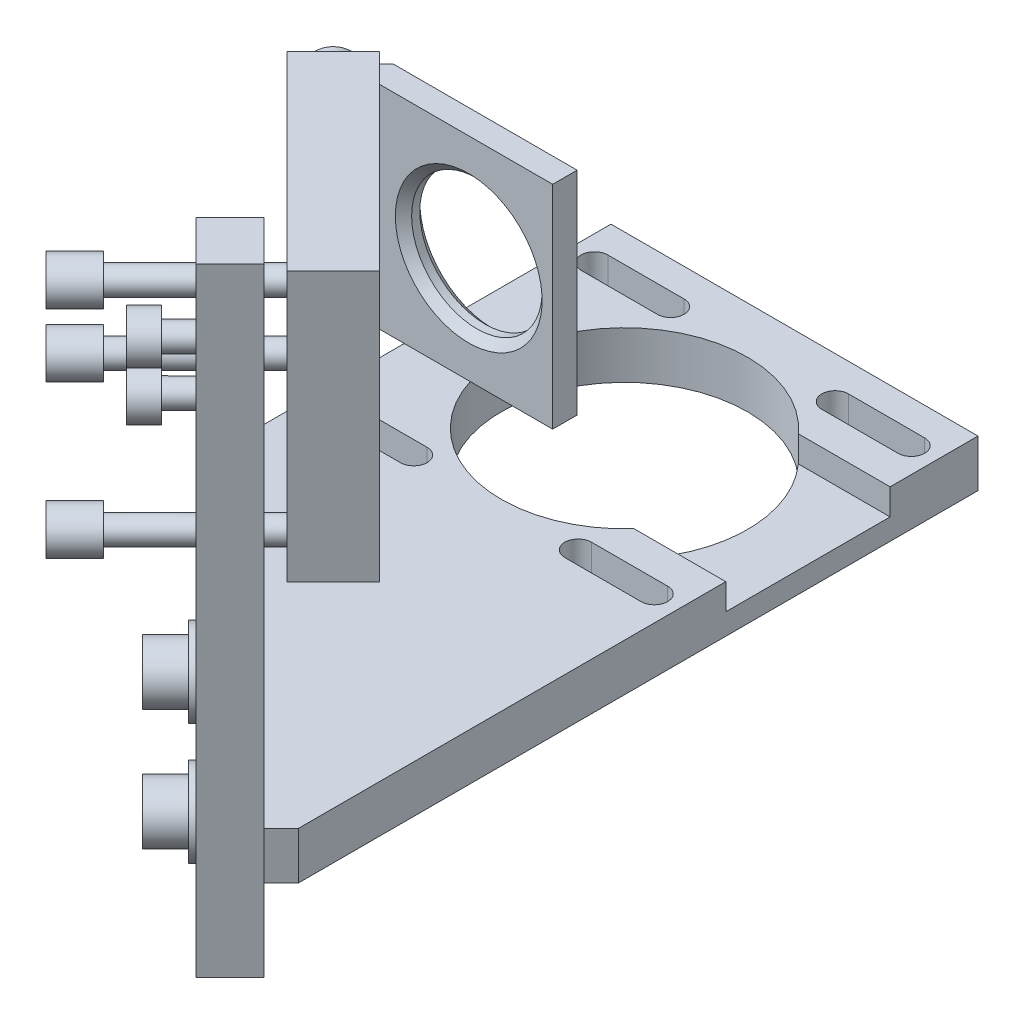
from build123d import *

# Parameters (mm, degrees)
SKETCH1_W                = 49.9
SKETCH1_H                = 49.9
BOSS_EXTRUDE1_DEPTH      = 6
BOSS_EXTRUDE2_DEPTH      = 5.9
SKETCH3_R                = 1.5
BOSS_EXTRUDE3_DEPTH      = 13
BOSS_EXTRUDE3_DEPTH_BACK = 14.9
SKETCH4_R                = 2.5
BOSS_EXTRUDE4_DEPTH      = 5
SKETCH5_R                = 1.5
BOSS_EXTRUDE5_DEPTH      = 3
SKETCH6_R                = 2.75
BOSS_EXTRUDE6_DEPTH      = 0.5
SKETCH7_R                = 2.75
BOSS_EXTRUDE7_DEPTH      = 2.5
SKETCH8_W                = 33
SKETCH8_H                = 33
SKETCH8_R                = 8.675
BOSS_EXTRUDE8_DEPTH      = 1
SKETCH9_W                = 33
SKETCH9_H                = 33
SKETCH9_R                = 10.15
BOSS_EXTRUDE9_DEPTH      = 7
SKETCH10_R               = 10
BOSS_EXTRUDE10_DEPTH     = 2
SKETCH11_R               = 10.15
SKETCH11_R_2             = 6
BOSS_EXTRUDE11_DEPTH     = 3
SKETCH12_R               = 2
CUT_EXTRUDE1_DEPTH       = 13
SKETCH13_R               = 4
CUT_EXTRUDE2_DEPTH       = 4
SKETCH14_R               = 3.5
BOSS_EXTRUDE12_DEPTH     = 1
SKETCH15_R               = 3.5
BOSS_EXTRUDE13_DEPTH     = 3
BOSS_EXTRUDE14_DEPTH     = 13
SKETCH17_R               = 8
CUT_EXTRUDE3_DEPTH       = 3
CHAMFER1_SIZE            = 1
SKETCH18_R               = 2.75
BOSS_EXTRUDE15_DEPTH     = 0.5
SKETCH19_R               = 2.75
BOSS_EXTRUDE16_DEPTH     = 2.5
SKETCH20_W               = 97.923574324
SKETCH20_H               = 110.172602672
CUT_EXTRUDE4_DEPTH       = 23
BOSS_EXTRUDE17_DEPTH     = 42
CUT_EXTRUDE5_DEPTH       = 35.775
SKETCH23_R               = 15.1
BOSS_EXTRUDE18_DEPTH     = 5.8
CUT_EXTRUDE6_DEPTH       = 3.2
SKETCH25_R               = 4.5
BOSS_EXTRUDE19_DEPTH     = 0.65
SKETCH26_R               = 3.25
BOSS_EXTRUDE20_DEPTH     = 1
SKETCH27_R               = 3.25
BOSS_EXTRUDE21_DEPTH     = 3


with BuildPart() as part:
    # Sketch1 → Boss-Extrude1 (new body)
    with BuildSketch(Plane(origin=(0, -32.5, 0), x_dir=(1, 0, 0), z_dir=(0, 1, 0))):
        with Locations((-9.95, -9.95)):
            Rectangle(SKETCH1_W, SKETCH1_H)
        with BuildLine():
            Line((1.05, 8.3), (10.05, 8.3))
            ThreePointArc((10.05, 8.3), (12.55, 5.8), (10.05, 3.3))
            Line((10.05, 3.3), (1.05, 3.3))
            ThreePointArc((1.05, 3.3), (-1.45, 5.8), (1.05, 8.3))
        make_face(mode=Mode.SUBTRACT)
        with BuildLine():
            Line((-20.95, 8.3), (-29.95, 8.3))
            ThreePointArc((-29.95, 8.3), (-32.45, 5.8), (-29.95, 3.3))
            Line((-29.95, 3.3), (-20.95, 3.3))
            ThreePointArc((-20.95, 3.3), (-18.45, 5.8), (-20.95, 8.3))
        make_face(mode=Mode.SUBTRACT)
        with BuildLine():
            Line((-20.95, -28.2), (-29.95, -28.2))
            ThreePointArc((-29.95, -28.2), (-32.45, -25.7), (-29.95, -23.2))
            Line((-29.95, -23.2), (-20.95, -23.2))
            ThreePointArc((-20.95, -23.2), (-18.45, -25.7), (-20.95, -28.2))
        make_face(mode=Mode.SUBTRACT)
        with BuildLine():
            Line((1.05, -28.2), (10.05, -28.2))
            ThreePointArc((10.05, -28.2), (12.55, -25.7), (10.05, -23.2))
            Line((10.05, -23.2), (1.05, -23.2))
            ThreePointArc((1.05, -23.2), (-1.45, -25.7), (1.05, -28.2))
        make_face(mode=Mode.SUBTRACT)
    extrude(amount=-BOSS_EXTRUDE1_DEPTH)

    # Sketch2 → Boss-Extrude2 (add)
    with BuildSketch(Plane(origin=(-6.363961031, 0, 6.363961031), x_dir=(0, -1, 0), z_dir=(0.707106781, 0, -0.707106781))):
        with BuildLine():
            Line((-5.545268253, -9.5), (-17.25, -9.5))
            Line((-17.25, -9.5), (-17.25, -16.5))
            Line((-17.25, -16.5), (32.5, -16.5))
            Line((32.5, -16.5), (32.5, 16.5))
            Line((32.5, 16.5), (8.9, 16.5))
            Line((8.9, 16.5), (8.9, 6.464518544))
            ThreePointArc((8.9, 6.464518544), (8.156593612, -7.380378083), (-5.545268253, -9.5))
        make_face()
    extrude(amount=-BOSS_EXTRUDE2_DEPTH)

    # Sketch3 → Boss-Extrude3 (add, two sides)
    with BuildSketch(Plane(origin=(-10.53589104, 0, 10.53589104), x_dir=(0.707106781, 0, 0.707106781), z_dir=(-0.707106781, 0, 0.707106781))) as boss_extrude3_sk:
        with Locations((13.25, 13.25)):
            Circle(SKETCH3_R)
        with Locations((13.25, -13.25)):
            Circle(SKETCH3_R)
        with Locations((-13.25, -13.25)):
            Circle(SKETCH3_R)
    extrude(amount=BOSS_EXTRUDE3_DEPTH)
    extrude(boss_extrude3_sk.sketch, amount=-BOSS_EXTRUDE3_DEPTH_BACK)

    # Sketch4 → Boss-Extrude4 (add)
    with BuildSketch(Plane(origin=(-19.728279195, 0, 19.728279195), x_dir=(0.707106781, 0, 0.707106781), z_dir=(-0.707106781, 0, 0.707106781))):
        with Locations((13.25, 13.25)):
            Circle(SKETCH4_R)
        with Locations((13.25, -13.25)):
            Circle(SKETCH4_R)
        with Locations((-13.25, -13.25)):
            Circle(SKETCH4_R)
    extrude(amount=-BOSS_EXTRUDE4_DEPTH)

    # Sketch5 → Boss-Extrude5 (add)
    with BuildSketch(Plane(origin=(-10.53589104, 0, 10.53589104), x_dir=(0.707106781, 0, 0.707106781), z_dir=(-0.707106781, 0, 0.707106781))):
        with Locations((-7.25, -13.25)):
            Circle(SKETCH5_R)
        with Locations((13.25, 7.25)):
            Circle(SKETCH5_R)
    extrude(amount=BOSS_EXTRUDE5_DEPTH)

    # Sketch6 → Boss-Extrude6 (add)
    with BuildSketch(Plane(origin=(-12.657211383, 0, 12.657211383), x_dir=(0.707106781, 0, 0.707106781), z_dir=(-0.707106781, 0, 0.707106781))):
        with Locations((13.25, 7.25)):
            Circle(SKETCH6_R)
        with Locations((-7.25, -13.25)):
            Circle(SKETCH6_R)
    extrude(amount=BOSS_EXTRUDE6_DEPTH)

    # Sketch7 → Boss-Extrude7 (add)
    with BuildSketch(Plane(origin=(-13.010764774, 0, 13.010764774), x_dir=(0.707106781, 0, 0.707106781), z_dir=(-0.707106781, 0, 0.707106781))):
        with Locations((-7.25, -13.25)):
            Circle(SKETCH7_R)
        Polygon((-6.221372178, -12.237449687), (-7.612580383, -11.852907018), (-8.641208205, -12.865457332), (-8.278627822, -14.262550313), (-6.887419617, -14.647092982), (-5.858791795, -13.634542668), align=None, mode=Mode.SUBTRACT)
        with Locations((13.25, 7.25)):
            Circle(SKETCH7_R)
        Polygon((13.787086733, 5.910271978), (14.678781868, 7.045266744), (14.141695135, 8.384994766), (12.712913267, 8.589728022), (11.821218132, 7.454733256), (12.358304865, 6.115005234), align=None, mode=Mode.SUBTRACT)
    extrude(amount=BOSS_EXTRUDE7_DEPTH)

    # Sketch8 → Boss-Extrude8 (add)
    with BuildSketch(Plane(origin=(0, 0, 0), x_dir=(0, -1, 0), z_dir=(0.707106781, 0, -0.707106781))):
        Rectangle(SKETCH8_W, SKETCH8_H)
        Circle(SKETCH8_R, mode=Mode.SUBTRACT)
    extrude(amount=BOSS_EXTRUDE8_DEPTH)

    # Sketch9 → Boss-Extrude9 (add)
    with BuildSketch(Plane(origin=(0, 0, 0), x_dir=(0.707106781, 0, 0.707106781), z_dir=(-0.707106781, 0, 0.707106781))):
        Rectangle(SKETCH9_W, SKETCH9_H)
        Circle(SKETCH9_R, mode=Mode.SUBTRACT)
    extrude(amount=BOSS_EXTRUDE9_DEPTH)

    # Sketch10 → Boss-Extrude10 (add)
    with BuildSketch(Plane(origin=(0, 0, 0), x_dir=(0.707106781, 0, 0.707106781), z_dir=(-0.707106781, 0, 0.707106781))):
        Circle(SKETCH10_R)
    extrude(amount=BOSS_EXTRUDE10_DEPTH)

    # Sketch11 → Boss-Extrude11 (add)
    with BuildSketch(Plane(origin=(-1.414213562, 0, 1.414213562), x_dir=(0.707106781, 0, 0.707106781), z_dir=(-0.707106781, 0, 0.707106781))):
        Circle(SKETCH11_R)
        Circle(SKETCH11_R_2, mode=Mode.SUBTRACT)
    extrude(amount=BOSS_EXTRUDE11_DEPTH)

    # Sketch12 → Cut-Extrude1 (cut)
    with BuildSketch(Plane.XZ.offset(38.5)):
        with Locations((-15.344217152, 1.555634919)):
            Circle(SKETCH12_R)
        with Locations((-1.555634919, 15.344217152)):
            Circle(SKETCH12_R)
    extrude(amount=-CUT_EXTRUDE1_DEPTH, mode=Mode.SUBTRACT)

    # Sketch13 → Cut-Extrude2 (cut)
    with BuildSketch(Plane.XZ.offset(38.5)):
        with Locations((-15.344217152, 1.555634919)):
            Circle(SKETCH13_R)
        with Locations((-1.555634919, 15.344217152)):
            Circle(SKETCH13_R)
    extrude(amount=-CUT_EXTRUDE2_DEPTH, mode=Mode.SUBTRACT)

    # Sketch14 → Boss-Extrude12 (add)
    with BuildSketch(Plane.XZ.offset(34.5)):
        with Locations((-15.344217152, 1.555634919)):
            Circle(SKETCH14_R)
        with Locations((-1.555634919, 15.344217152)):
            Circle(SKETCH14_R)
    extrude(amount=BOSS_EXTRUDE12_DEPTH)

    # Sketch15 → Boss-Extrude13 (add)
    with BuildSketch(Plane.XZ.offset(35.5)):
        with Locations((-1.555634919, 15.344217152)):
            Circle(SKETCH15_R)
        Polygon((-2.665434879, 16.674008131), (-3.262167668, 15.047997683), (-2.152367708, 13.718206703), (-0.445834958, 14.014426173), (0.150897831, 15.640436621), (-0.958902129, 16.9702276), align=None, mode=Mode.SUBTRACT)
        with Locations((-15.344217152, 1.555634919)):
            Circle(SKETCH15_R)
        Polygon((-14.297928697, 2.935953893), (-16.016464221, 3.151906787), (-17.062752676, 1.771587813), (-16.390505606, 0.175315945), (-14.671970082, -0.04063695), (-13.625681628, 1.339682024), align=None, mode=Mode.SUBTRACT)
    extrude(amount=BOSS_EXTRUDE13_DEPTH)

    # Sketch16 → Boss-Extrude14 (add, symmetric)
    with BuildSketch(Plane(origin=(0, 0, 0), x_dir=(1, 0, 0), z_dir=(0, 1, 0))):
        Polygon((-10.960155108, 12.374368671), (-16.263455967, 7.071067812), (-18.384776311, 9.192388155), (-12.202795796, 15.374368671), (10.289844892, 15.374368671), (10.289844892, 12.374368671), align=None)
    extrude(amount=BOSS_EXTRUDE14_DEPTH, both=True)

    # Sketch17 → Cut-Extrude3 (cut)
    with BuildSketch(Plane(origin=(0, 0, -15.374368671), x_dir=(-1, 0, 0), z_dir=(0, 0, -1))):
        Circle(SKETCH17_R)
    extrude(amount=-CUT_EXTRUDE3_DEPTH, mode=Mode.SUBTRACT)

    # Chamfer1
    chamfer1_edges = [part.edges().sort_by_distance(p)[0] for p in [
        (8, 0, -12.374368671),
        (8, 0, -15.374368671),
    ]]
    chamfer(chamfer1_edges, length=CHAMFER1_SIZE)

    # Sketch18 → Boss-Extrude15 (add)
    with BuildSketch(Plane(origin=(-13.788582233, 0, -13.788582233), x_dir=(-0.707106781, 0, 0.707106781), z_dir=(-0.707106781, 0, -0.707106781))):
        with Locations((3, 10)):
            Circle(SKETCH18_R)
        with Locations((3, -10)):
            Circle(SKETCH18_R)
    extrude(amount=BOSS_EXTRUDE15_DEPTH)

    # Sketch19 → Boss-Extrude16 (add)
    with BuildSketch(Plane(origin=(-14.142135624, 0, -14.142135624), x_dir=(-0.707106781, 0, 0.707106781), z_dir=(-0.707106781, 0, -0.707106781))):
        with Locations((3, -10)):
            Circle(SKETCH19_R)
        Polygon((3.666920263, -11.280058865), (4.442023626, -10.062459543), (3.775103364, -8.782400678), (2.333079737, -8.719941135), (1.557976374, -9.937540457), (2.224896636, -11.217599322), align=None, mode=Mode.SUBTRACT)
        with Locations((3, 10)):
            Circle(SKETCH19_R)
        Polygon((1.848210491, 9.130106754), (3.177454895, 8.567574402), (4.329244404, 9.437467649), (4.151789509, 10.869893246), (2.822545105, 11.432425598), (1.670755596, 10.562532351), align=None, mode=Mode.SUBTRACT)
    extrude(amount=BOSS_EXTRUDE16_DEPTH)

    # Sketch20 → Cut-Extrude4 (cut, through all)
    with BuildSketch(Plane.XZ.offset(16.5)):
        with Locations((-16.066182646, 3.970949748)):
            Rectangle(SKETCH20_W, SKETCH20_H)
    extrude(amount=CUT_EXTRUDE4_DEPTH, mode=Mode.SUBTRACT)

    # Sketch21 → Boss-Extrude17 (add)
    with BuildSketch(Plane.XZ.offset(16.5)):
        Polygon((-22.203152929, -1.13137085), (-18.03122292, -5.303300859), (5.303300859, 18.03122292), (1.13137085, 22.203152929), align=None)
    extrude(amount=BOSS_EXTRUDE17_DEPTH)

    # Sketch22 → Cut-Extrude5 (cut, through all)
    with BuildSketch(Plane(origin=(-10.53589104, 0, 10.53589104), x_dir=(0.707106781, 0, 0.707106781), z_dir=(-0.707106781, 0, 0.707106781))):
        with BuildLine():
            Line((8, -54.15), (8, -45.15))
            ThreePointArc((8, -45.15), (10.5, -42.65), (13, -45.15))
            Line((13, -45.15), (13, -54.15))
            ThreePointArc((13, -54.15), (10.5, -56.65), (8, -54.15))
        make_face()
        with BuildLine():
            Line((-8, -54.15), (-8, -45.15))
            ThreePointArc((-8, -45.15), (-10.5, -42.65), (-13, -45.15))
            Line((-13, -45.15), (-13, -54.15))
            ThreePointArc((-13, -54.15), (-10.5, -56.65), (-8, -54.15))
        make_face()
    extrude(amount=-CUT_EXTRUDE5_DEPTH, mode=Mode.SUBTRACT)

    # Sketch23 → Boss-Extrude18 (add)
    with BuildSketch(Plane(origin=(0, -41.75, 0), x_dir=(-1, 0, 0), z_dir=(0, -1, 0))):
        Polygon((36.656139982, 23.928217921), (-6.222539674, -18.950461736), (-8.343860018, -16.829141392), (-8.343860018, 66.46877708), (36.656139982, 66.46877708), align=None)
        with Locations((14.156139982, 45.61877708)):
            Circle(SKETCH23_R, mode=Mode.SUBTRACT)
        with BuildLine():
            Line((33.576358301, 59.732214218), (24.235921663, 59.732214218))
            ThreePointArc((24.235921663, 59.732214218), (22.599358801, 61.36877708), (24.235921663, 63.005339941))
            Line((24.235921663, 63.005339941), (33.576358301, 63.005339941))
            ThreePointArc((33.576358301, 63.005339941), (35.212921163, 61.36877708), (33.576358301, 59.732214218))
        make_face(mode=Mode.SUBTRACT)
        with BuildLine():
            Line((-5.264078337, 59.732214218), (4.076358301, 59.732214218))
            ThreePointArc((4.076358301, 59.732214218), (5.712921163, 61.36877708), (4.076358301, 63.005339941))
            Line((4.076358301, 63.005339941), (-5.264078337, 63.005339941))
            ThreePointArc((-5.264078337, 63.005339941), (-6.900641199, 61.36877708), (-5.264078337, 59.732214218))
        make_face(mode=Mode.SUBTRACT)
        with BuildLine():
            Line((33.576358301, 31.505339941), (24.235921663, 31.505339941))
            ThreePointArc((24.235921663, 31.505339941), (22.599358801, 29.86877708), (24.235921663, 28.232214218))
            Line((24.235921663, 28.232214218), (33.576358301, 28.232214218))
            ThreePointArc((33.576358301, 28.232214218), (35.212921163, 29.86877708), (33.576358301, 31.505339941))
        make_face(mode=Mode.SUBTRACT)
        with BuildLine():
            Line((-5.264078337, 31.505339941), (4.076358301, 31.505339941))
            ThreePointArc((4.076358301, 31.505339941), (5.712921163, 29.86877708), (4.076358301, 28.232214218))
            Line((4.076358301, 28.232214218), (-5.264078337, 28.232214218))
            ThreePointArc((-5.264078337, 28.232214218), (-6.900641199, 29.86877708), (-5.264078337, 31.505339941))
        make_face(mode=Mode.SUBTRACT)
    extrude(amount=BOSS_EXTRUDE18_DEPTH)

    # Sketch24 → Cut-Extrude6 (cut)
    with BuildSketch(Plane(origin=(0, -41.75, 0), x_dir=(1, 0, 0), z_dir=(0, 1, 0))):
        with BuildLine():
            Line((8.343860018, 55.69377708), (8.343860018, 35.54377708))
            Line((8.343860018, 35.54377708), (-2.908723612, 35.54377708))
            ThreePointArc((-2.908723612, 35.54377708), (0.943860018, 45.61877708), (-2.908723612, 55.69377708))
            Line((-2.908723612, 55.69377708), (8.343860018, 55.69377708))
        make_face()
    extrude(amount=-CUT_EXTRUDE6_DEPTH, mode=Mode.SUBTRACT)

    # Sketch25 → Boss-Extrude19 (add)
    with BuildSketch(Plane(origin=(-10.53589104, 0, 10.53589104), x_dir=(0.707106781, 0, 0.707106781), z_dir=(-0.707106781, 0, 0.707106781))):
        with Locations((-10.5, -45.15)):
            Circle(SKETCH25_R)
        with Locations((10.5, -45.15)):
            Circle(SKETCH25_R)
    extrude(amount=BOSS_EXTRUDE19_DEPTH)

    # Sketch26 → Boss-Extrude20 (add)
    with BuildSketch(Plane(origin=(-10.995510447, 0, 10.995510447), x_dir=(0.707106781, 0, 0.707106781), z_dir=(-0.707106781, 0, 0.707106781))):
        with Locations((-10.5, -45.15)):
            Circle(SKETCH26_R)
        with Locations((10.5, -45.15)):
            Circle(SKETCH26_R)
    extrude(amount=BOSS_EXTRUDE20_DEPTH)

    # Sketch27 → Boss-Extrude21 (add)
    with BuildSketch(Plane(origin=(-11.702617229, 0, 11.702617229), x_dir=(0.707106781, 0, 0.707106781), z_dir=(-0.707106781, 0, 0.707106781))):
        with Locations((10.5, -45.15)):
            Circle(SKETCH27_R)
        Polygon((11.560104341, -46.519736758), (12.216278999, -44.916791089), (11.156174658, -43.547054331), (9.439895659, -43.780263242), (8.783721001, -45.383208911), (9.843825342, -46.752945669), align=None, mode=Mode.SUBTRACT)
        with Locations((-10.5, -45.15)):
            Circle(SKETCH27_R)
        Polygon((-8.910670537, -45.838499715), (-9.109077025, -44.117850168), (-10.698406488, -43.429350452), (-12.089329463, -44.461500285), (-11.890922975, -46.182149832), (-10.301593512, -46.870649548), align=None, mode=Mode.SUBTRACT)
    extrude(amount=BOSS_EXTRUDE21_DEPTH)


solid = part.part
